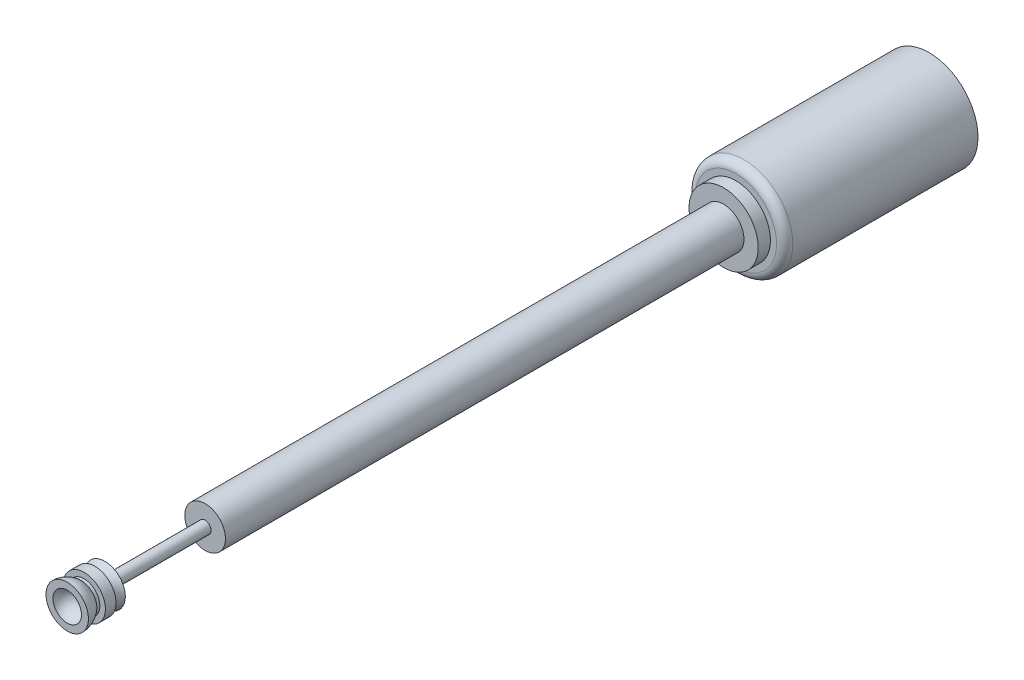
from build123d import *

# Parameters (mm, degrees)
SKETCH1_R           = 0.5
BOSS_EXTRUDE1_DEPTH = 15.5
SKETCH1_3_R         = 1.2
BOSS_EXTRUDE2_DEPTH = 4.75
FILLET1_R           = 0.2
SKETCH8_W           = 0.783973705
SKETCH8_H           = 2.46
SKETCH9_R           = 0.85
BOSS_EXTRUDE5_DEPTH = 0.3


with BuildPart() as part:
    # Sketch1 → Boss-Extrude1 (new body)
    with BuildSketch(Plane.XY):
        Circle(SKETCH1_R)
    extrude(amount=BOSS_EXTRUDE1_DEPTH)

    # Sketch8 → Cut-Revolve2 (revolve, cut)
    with BuildSketch(Plane(origin=(0, 0, 0), x_dir=(1, 0, 0), z_dir=(0, 1, 0))):
        with Locations((-0.540086852, -14.27)):
            Rectangle(SKETCH8_W, SKETCH8_H)
    revolve(axis=Axis((0, 0, 15.5), (0, 0, 1)), mode=Mode.SUBTRACT)



with BuildPart() as body_2:
    # Sketch1_3 → Boss-Extrude2 (new body)
    with BuildSketch(Plane.XY):
        Circle(SKETCH1_3_R)
    extrude(amount=-BOSS_EXTRUDE2_DEPTH)

    # Fillet1
    fillet1_edges = [body_2.edges().sort_by_distance(p)[0] for p in [
        (-1.2, 0, 0),
    ]]
    fillet(fillet1_edges, radius=FILLET1_R)


with BuildPart() as body_3:
    # Sketch3 → Revolve1 (revolve)
    with BuildSketch(Plane(origin=(0, 0, 0), x_dir=(1, 0, 0), z_dir=(0, 1, 0))):
        with BuildLine():
            Line((0.5, -15.5), (0, -15.5))
            Line((0, -15.5), (0, -16.0775))
            ThreePointArc((0, -16.0775), (0.247487373, -16.180012627), (0.35, -16.4275))
            Line((0.35, -16.4275), (0.521160332, -16.4275))
            ThreePointArc((0.521160332, -16.4275), (0.485718669, -16.242606648), (0.384418127, -16.083925008))
            Line((0.384418127, -16.083925008), (0.384418127, -16.010569997))
            Line((0.384418127, -16.010569997), (0.521160332, -16.010569997))
            Line((0.521160332, -16.010569997), (0.521160332, -15.749819222))
            Line((0.521160332, -15.749819222), (0.40822727, -15.749819222))
            ThreePointArc((0.40822727, -15.749819222), (0.4318963, -15.616747927), (0.5, -15.5))
        make_face()
    revolve(axis=Axis((0, 0, 15.5), (0, 0, 1)))


with BuildPart() as part_1:
    add(part.part)

    add(body_2.part)  # Boss-Extrude5 merges body 2
    # Sketch9 → Boss-Extrude5 (add)
    with BuildSketch(Plane.XY):
        Circle(SKETCH9_R)
    extrude(amount=BOSS_EXTRUDE5_DEPTH)


solid = Compound([body_3.part, part_1.part])
